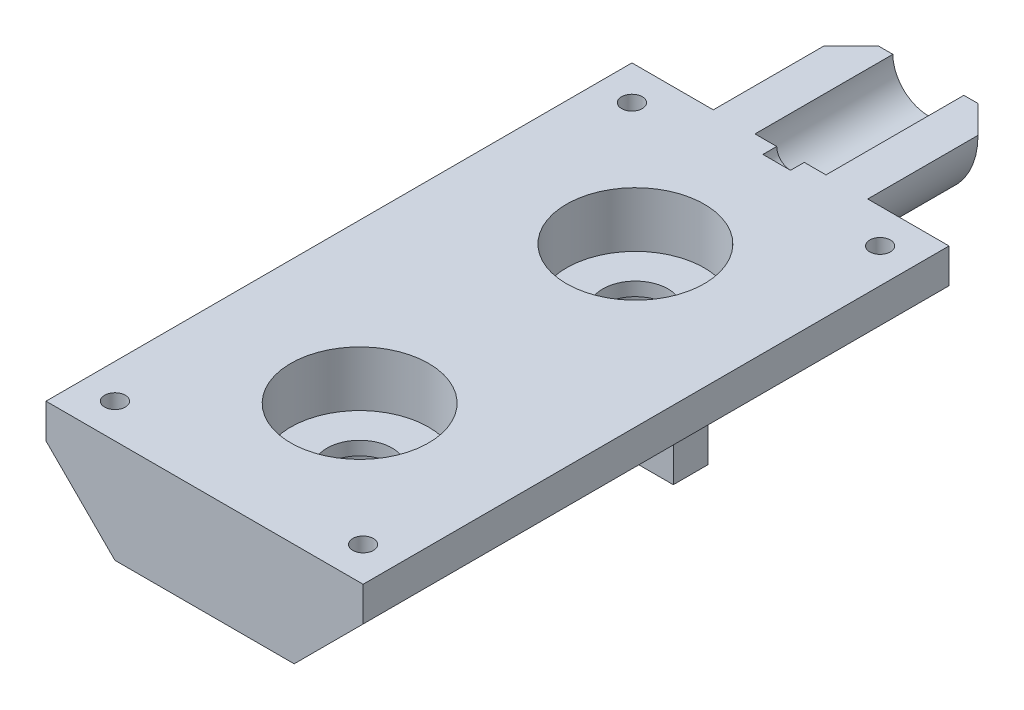
from build123d import *

# Parameters (mm, degrees)
SKETCH1_W           = 58.42
SKETCH1_H           = 107.95
BOSS_EXTRUDE1_DEPTH = 38.1
CHAMFER1_SIZE       = 12.7
CHAMFER2_SIZE       = 12.7
SKETCH2_R           = 14.224
SKETCH2_R_2         = 6.5405
BOSS_EXTRUDE2_DEPTH = 25.4
CHAMFER3_SIZE       = 5.08
SKETCH3_W           = 58.42
SKETCH3_H           = 22.12413995
CUT_EXTRUDE1_DEPTH  = 152.4
SKETCH4_R           = 8.85
CUT_EXTRUDE2_DEPTH  = 6.4
SKETCH5_R           = 6
CUT_EXTRUDE3_DEPTH  = 17.16
SKETCH6_R           = 12.7
CUT_EXTRUDE4_DEPTH  = 10.16
SKETCH7_R           = 2.54
CUT_EXTRUDE5_DEPTH  = 2.54
SKETCH9_R           = 1.27
CUT_EXTRUDE7_DEPTH  = 5.08
SKETCH10_W          = 6.35
SKETCH10_H          = 6.35
SKETCH10_R          = 1.27
BOSS_EXTRUDE3_DEPTH = 7.62
SKETCH11_R          = 1.27
CUT_EXTRUDE8_DEPTH  = 5.08
SKETCH12_W          = 10.16
SKETCH12_H          = 6.35
BOSS_EXTRUDE4_DEPTH = 12.7
SKETCH13_R          = 1.27
CUT_EXTRUDE9_DEPTH  = 5.08
SKETCH14_R          = 1.905
CUT_EXTRUDE10_DEPTH = 40.64
SKETCH15_R          = 2.921
CUT_EXTRUDE11_DEPTH = 15.24


with BuildPart() as part:
    # Sketch1 → Boss-Extrude1 (new body)
    with BuildSketch(Plane(origin=(0, 0, 0), x_dir=(1, 0, 0), z_dir=(0, 1, 0))):
        Rectangle(SKETCH1_W, SKETCH1_H)
    extrude(amount=BOSS_EXTRUDE1_DEPTH)

    # Chamfer1
    chamfer1_edges = [part.edges().sort_by_distance(p)[0] for p in [
        (-29.21, 38.1, 0),
    ]]
    chamfer(chamfer1_edges, length=CHAMFER1_SIZE)

    # Chamfer2
    chamfer2_edges = [part.edges().sort_by_distance(p)[0] for p in [
        (29.21, 38.1, 0),
        (-29.21, 0, 0),
        (29.21, 0, 0),
    ]]
    chamfer(chamfer2_edges, length=CHAMFER2_SIZE)

    # Sketch2 → Boss-Extrude2 (add)
    with BuildSketch(Plane(origin=(0, 0, -53.975), x_dir=(-1, 0, 0), z_dir=(0, 0, -1))):
        with Locations((0, 19.05)):
            Circle(SKETCH2_R)
        with Locations((0, 19.05)):
            Circle(SKETCH2_R_2, mode=Mode.SUBTRACT)
    extrude(amount=BOSS_EXTRUDE2_DEPTH)

    # Chamfer3
    chamfer3_edges = [part.edges().sort_by_distance(p)[0] for p in [
        (14.224, 19.05, -79.375),
    ]]
    chamfer(chamfer3_edges, length=CHAMFER3_SIZE)

    # Sketch3 → Cut-Extrude1 (cut)
    with BuildSketch(Plane.XY.offset(53.975)):
        with Locations((0, 30.112069975)):
            Rectangle(SKETCH3_W, SKETCH3_H)
    cut_extrude1 = extrude(amount=-CUT_EXTRUDE1_DEPTH, mode=Mode.SUBTRACT)

    # Sketch4 → Cut-Extrude2 (cut)
    with BuildSketch(Plane(origin=(0, 0, 0), x_dir=(-1, 0, 0), z_dir=(0, -1, 0))):
        with Locations((0, 25.4)):
            Circle(SKETCH4_R)
    cut_extrude2 = extrude(amount=-CUT_EXTRUDE2_DEPTH, mode=Mode.SUBTRACT)

    # Sketch5 → Cut-Extrude3 (cut)
    with BuildSketch(Plane.XZ.offset(-6.4)):
        with Locations((0, -25.4)):
            Circle(SKETCH5_R)
    cut_extrude3 = extrude(amount=-CUT_EXTRUDE3_DEPTH, mode=Mode.SUBTRACT)

    # Sketch6 → Cut-Extrude4 (cut)
    with BuildSketch(Plane(origin=(0, 19.05, 0), x_dir=(1, 0, 0), z_dir=(0, 1, 0))):
        with Locations((0, 25.4)):
            Circle(SKETCH6_R)
    cut_extrude4 = extrude(amount=-CUT_EXTRUDE4_DEPTH, mode=Mode.SUBTRACT)

    # Mirror1: Cut-Extrude1, Cut-Extrude2, Cut-Extrude3, Cut-Extrude4 across plane
    add(cut_extrude1.mirror(Plane.XY), mode=Mode.SUBTRACT)
    add(cut_extrude2.mirror(Plane.XY), mode=Mode.SUBTRACT)
    add(cut_extrude3.mirror(Plane.XY), mode=Mode.SUBTRACT)
    add(cut_extrude4.mirror(Plane.XY), mode=Mode.SUBTRACT)

    # Sketch7 → Cut-Extrude5 (cut)
    with BuildSketch(Plane(origin=(0, 0, -53.975), x_dir=(-1, 0, 0), z_dir=(0, 0, -1))):
        with Locations((0, 19.05)):
            Circle(SKETCH7_R)
    extrude(amount=-CUT_EXTRUDE5_DEPTH, mode=Mode.SUBTRACT)

    # Sketch9 → Cut-Extrude7 (cut)
    with BuildSketch(Plane(origin=(0, 0, 0), x_dir=(-1, 0, 0), z_dir=(0, -1, 0))):
        with Locations((0, 44.45)):
            Circle(SKETCH9_R)
        with Locations((0, -50.8)):
            Circle(SKETCH9_R)
    extrude(amount=-CUT_EXTRUDE7_DEPTH, mode=Mode.SUBTRACT)

    # Sketch10 → Boss-Extrude3 (add)
    with BuildSketch(Plane(origin=(0, 0, 0), x_dir=(-1, 0, 0), z_dir=(0, -1, 0))):
        with Locations((-19.685, 12.7)):
            Rectangle(SKETCH10_W, SKETCH10_H)
        with Locations((-19.685, 12.7)):
            Circle(SKETCH10_R, mode=Mode.SUBTRACT)
    extrude(amount=-BOSS_EXTRUDE3_DEPTH)

    # Sketch11 → Cut-Extrude8 (cut)
    with BuildSketch(Plane(origin=(0, 0, 0), x_dir=(-1, 0, 0), z_dir=(0, -1, 0))):
        with Locations((-19.685, 12.7)):
            Circle(SKETCH11_R)
    extrude(amount=-CUT_EXTRUDE8_DEPTH, mode=Mode.SUBTRACT)

    # Sketch14 → Cut-Extrude10 (cut)
    with BuildSketch(Plane(origin=(0, 19.05, 0), x_dir=(1, 0, 0), z_dir=(0, 1, 0))):
        with Locations((22.86, 47.625)):
            Circle(SKETCH14_R)
        with Locations((-22.86, 47.625)):
            Circle(SKETCH14_R)
    cut_extrude10 = extrude(amount=-CUT_EXTRUDE10_DEPTH, mode=Mode.SUBTRACT)

    # Mirror2: Cut-Extrude10 across plane
    add(cut_extrude10.mirror(Plane.XY), mode=Mode.SUBTRACT)

    # Sketch15 → Cut-Extrude11 (cut)
    with BuildSketch(Plane(origin=(0, 0, 0), x_dir=(-1, 0, 0), z_dir=(0, -1, 0))):
        with Locations((22.86, 47.625)):
            Circle(SKETCH15_R)
        with Locations((-22.86, 47.625)):
            Circle(SKETCH15_R)
        with Locations((-22.86, -47.625)):
            Circle(SKETCH15_R)
        with Locations((22.86, -47.625)):
            Circle(SKETCH15_R)
    extrude(amount=-CUT_EXTRUDE11_DEPTH, mode=Mode.SUBTRACT)


with BuildPart() as body_2:
    # Sketch12 → Boss-Extrude4 (new body)
    with BuildSketch(Plane(origin=(0, 0, 0), x_dir=(-1, 0, 0), z_dir=(0, -1, 0))):
        with Locations((21.59, -13.335)):
            Rectangle(SKETCH12_W, SKETCH12_H)
    extrude(amount=-BOSS_EXTRUDE4_DEPTH)

    # Sketch13 → Cut-Extrude9 (cut)
    with BuildSketch(Plane(origin=(0, 0, 0), x_dir=(-1, 0, 0), z_dir=(0, -1, 0))):
        with Locations((22.86, -13.335)):
            Circle(SKETCH13_R)
    extrude(amount=-CUT_EXTRUDE9_DEPTH, mode=Mode.SUBTRACT)


solid = Compound([part.part, body_2.part])
